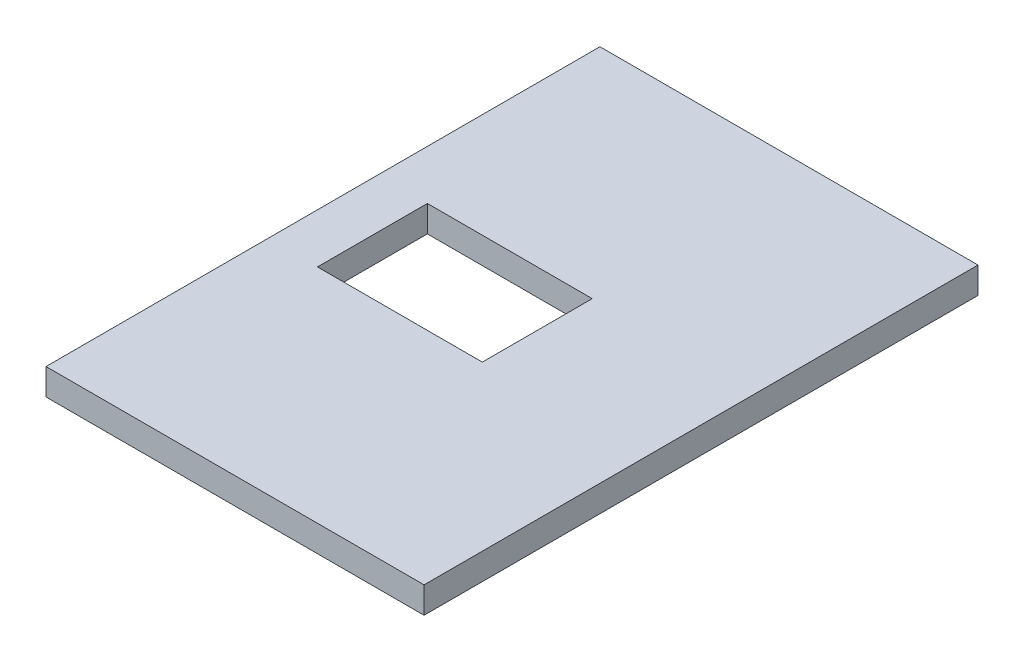
from build123d import *

# Parameters (mm, degrees)
CROQUIS1_W              = 1620
CROQUIS1_H              = 2520
SALIENTE_EXTRUIR1_DEPTH = 120
CROQUIS2_W              = 750
CROQUIS2_H              = 500
CORTAR_EXTRUIR1_DEPTH   = 120
CROQUIS3_W              = 2520
CROQUIS3_H              = 120
SALIENTE_EXTRUIR2_DEPTH = 100


with BuildPart() as part:
    # Croquis1 → Saliente-Extruir1 (new body)
    with BuildSketch(Plane(origin=(0, 0, 0), x_dir=(1, 0, 0), z_dir=(0, 1, 0))):
        Rectangle(CROQUIS1_W, CROQUIS1_H)
    extrude(amount=SALIENTE_EXTRUIR1_DEPTH)

    # Croquis2 → Cortar-Extruir1 (cut)
    with BuildSketch(Plane(origin=(0, 120, 0), x_dir=(1, 0, 0), z_dir=(0, 1, 0))):
        with Locations((-310, 0)):
            Rectangle(CROQUIS2_W, CROQUIS2_H)
    extrude(amount=-CORTAR_EXTRUIR1_DEPTH, mode=Mode.SUBTRACT)

    # Croquis3 → Saliente-Extruir2 (add)
    with BuildSketch(Plane.ZY.offset(810)):
        with Locations((0, 60)):
            Rectangle(CROQUIS3_W, CROQUIS3_H)
    extrude(amount=SALIENTE_EXTRUIR2_DEPTH)


solid = part.part
